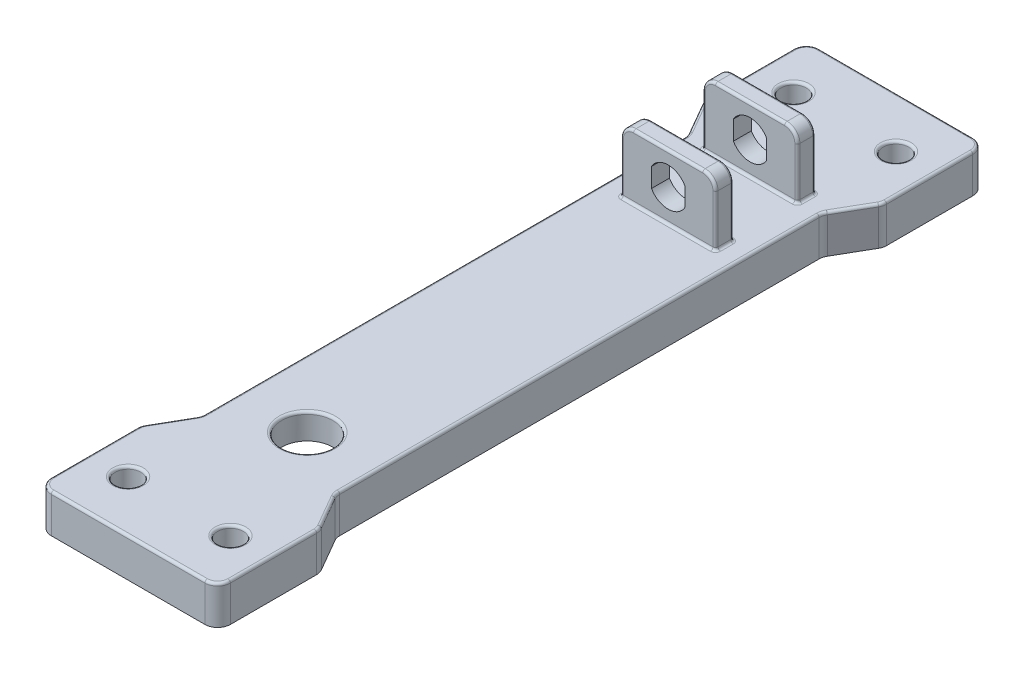
from build123d import *

# Parameters (mm, degrees)
BOSS_EXTRUDE1_DEPTH     = 15
FILLET1_R               = 5
CUT_EXTRUDE1_DEPTH      = 5
SKETCH3_W               = 37
SKETCH3_H               = 7
BOSS_EXTRUDE2_DEPTH     = 25
FILLET2_R               = 5
FILLET3_R               = 1
CUT_EXTRUDE2_DEPTH      = 212
CUT_EXTRUDE2_DEPTH_BACK = 90
SKETCH6_R               = 5
SKETCH6_R_2             = 10
CUT_EXTRUDE3_DEPTH      = 26.0000001
CUT_EXTRUDE3_DEPTH_BACK = 16
FILLET4_R               = 1


with BuildPart() as part:
    # Sketch1 → Boss-Extrude1 (new body)
    with BuildSketch(Plane(origin=(0, 0, 0), x_dir=(1, 0, 0), z_dir=(0, 1, 0))):
        Polygon((-35, 150), (35, 150), (35, 110), (26.339745962, 95), (26.339745962, -95), (35, -110), (35, -150), (-35, -150), (-35, -110), (-26.339745962, -95), (-26.339745962, 95), (-35, 110), align=None)
    extrude(amount=BOSS_EXTRUDE1_DEPTH)

    # Fillet1
    fillet1_edges = [part.edges().sort_by_distance(p)[0] for p in [
        (35, 7.5, 150),
        (-35, 7.5, 150),
        (-35, 7.5, 110),
        (-26.339745962, 7.5, 95),
        (-26.339745962, 7.5, -95),
        (-35, 7.5, -110),
        (-35, 7.5, -150),
        (35, 7.5, -150),
        (35, 7.5, -110),
        (26.339745962, 7.5, -95),
        (26.339745962, 7.5, 95),
        (35, 7.5, 110),
    ]]
    fillet(fillet1_edges, radius=FILLET1_R)

    # Sketch2 → Cut-Extrude1 (cut)
    with BuildSketch(Plane.XZ):
        with BuildLine():
            Line((25, 140), (-25, 140))
            Line((-25, 140), (-25, 112.679491924))
            Line((-25, 112.679491924), (-18.349364905, 101.160254038))
            ThreePointArc((-18.349364905, 101.160254038), (-16.850858568, 97.542539714), (-16.339745962, 93.660254038))
            Line((-16.339745962, 93.660254038), (-16.339745962, -93.660254038))
            ThreePointArc((-16.339745962, -93.660254038), (-16.850858568, -97.542539714), (-18.349364905, -101.160254038))
            Line((-18.349364905, -101.160254038), (-25, -112.679491924))
            Line((-25, -112.679491924), (-25, -140))
            Line((-25, -140), (25, -140))
            Line((25, -140), (25, -112.679491924))
            Line((25, -112.679491924), (18.349364905, -101.160254038))
            ThreePointArc((18.349364905, -101.160254038), (16.850858568, -97.542539714), (16.339745962, -93.660254038))
            Line((16.339745962, -93.660254038), (16.339745962, 93.660254038))
            ThreePointArc((16.339745962, 93.660254038), (16.850858568, 97.542539714), (18.349364905, 101.160254038))
            Line((18.349364905, 101.160254038), (25, 112.679491924))
            Line((25, 112.679491924), (25, 140))
        make_face()
    extrude(amount=-CUT_EXTRUDE1_DEPTH, mode=Mode.SUBTRACT)

    # Sketch3 → Boss-Extrude2 (add)
    with BuildSketch(Plane(origin=(0, 15, 0), x_dir=(1, 0, 0), z_dir=(0, 1, 0))):
        with Locations((0, 96.5)):
            Rectangle(SKETCH3_W, SKETCH3_H)
        with Locations((0, 64.5)):
            Rectangle(SKETCH3_W, SKETCH3_H)
    extrude(amount=BOSS_EXTRUDE2_DEPTH)

    # Fillet2
    fillet2_edges = [part.edges().sort_by_distance(p)[0] for p in [
        (18.5, 40, -96.5),
        (-18.5, 40, -96.5),
        (18.5, 40, -64.5),
        (-18.5, 40, -64.5),
    ]]
    fillet(fillet2_edges, radius=FILLET2_R)

    # Fillet3
    fillet3_edges = [part.edges().sort_by_distance(p)[0] for p in [
        (18.5, 15, -96.5),
        (0, 15, -100),
        (-18.5, 15, -96.5),
        (0, 15, -93),
        (18.5, 15, -64.5),
        (0, 15, -68),
        (-18.5, 15, -64.5),
        (0, 15, -61),
        (0, 40, -68),
        (0, 40, -61),
        (-18.5, 25, -68),
        (18.5, 25, -68),
        (-17.035533906, 38.535533906, -68),
        (17.035533906, 38.535533906, -68),
        (18.5, 25, -61),
        (-18.5, 25, -61),
        (-17.035533906, 38.535533906, -61),
        (17.035533906, 38.535533906, -61),
        (0, 40, -100),
        (0, 40, -93),
        (-18.5, 25, -100),
        (18.5, 25, -100),
        (-17.035533906, 38.535533906, -100),
        (17.035533906, 38.535533906, -100),
        (18.5, 25, -93),
        (-18.5, 25, -93),
        (-17.035533906, 38.535533906, -93),
        (17.035533906, 38.535533906, -93),
    ]]
    fillet(fillet3_edges, radius=FILLET3_R)

    # Sketch5 → Cut-Extrude2 (cut, two sides)
    with BuildSketch(Plane.XY.offset(-61)) as cut_extrude2_sk:
        with BuildLine():
            Line((-6.5, 31.241657387), (-6.5, 23.758342613))
            ThreePointArc((-6.5, 23.758342613), (0, 20), (6.5, 23.758342613))
            Line((6.5, 23.758342613), (6.5, 31.241657387))
            ThreePointArc((6.5, 31.241657387), (0, 35), (-6.5, 31.241657387))
        make_face()
    extrude(amount=CUT_EXTRUDE2_DEPTH, mode=Mode.SUBTRACT)
    extrude(cut_extrude2_sk.sketch, amount=-CUT_EXTRUDE2_DEPTH_BACK, mode=Mode.SUBTRACT)

    # Sketch6 → Cut-Extrude3 (cut, two sides)
    with BuildSketch(Plane(origin=(0, 15, 0), x_dir=(1, 0, 0), z_dir=(0, 1, 0))) as cut_extrude3_sk:
        with Locations((-20, 130)):
            Circle(SKETCH6_R)
        with Locations((20, 130)):
            Circle(SKETCH6_R)
        with Locations((20, -130)):
            Circle(SKETCH6_R)
        with Locations((-20, -130)):
            Circle(SKETCH6_R)
        with Locations((0, -80)):
            Circle(SKETCH6_R_2)
    extrude(amount=CUT_EXTRUDE3_DEPTH, mode=Mode.SUBTRACT)
    extrude(cut_extrude3_sk.sketch, amount=-CUT_EXTRUDE3_DEPTH_BACK, mode=Mode.SUBTRACT)

    # Fillet4
    fillet4_edges = [part.edges().sort_by_distance(p)[0] for p in [
        (-10, 15, 80),
        (-25, 15, 130),
        (15, 15, 130),
        (15, 15, -130),
        (-25, 15, -130),
        (0, 15, 150),
        (-35, 15, 128.169872981),
        (35, 15, 128.169872981),
        (30.669872981, 15, 102.5),
        (26.339745962, 15, 0),
        (30.669872981, 15, -102.5),
        (35, 15, -128.169872981),
        (0, 15, -150),
        (-35, 15, -128.169872981),
        (-30.669872981, 15, -102.5),
        (-26.339745962, 15, 0),
        (-30.669872981, 15, 102.5),
        (33.535533906, 15, 148.535533906),
        (34.829629131, 15, 110.045650737),
        (34.829629131, 15, -110.045650737),
        (33.535533906, 15, -148.535533906),
        (-33.535533906, 15, -148.535533906),
        (-34.829629131, 15, -110.045650737),
        (-34.829629131, 15, 110.045650737),
        (-33.535533906, 15, 148.535533906),
        (-26.510116831, 15, 94.954349263),
        (-26.510116831, 15, -94.954349263),
        (26.510116831, 15, -94.954349263),
        (26.510116831, 15, 94.954349263),
    ]]
    fillet(fillet4_edges, radius=FILLET4_R)


solid = part.part
